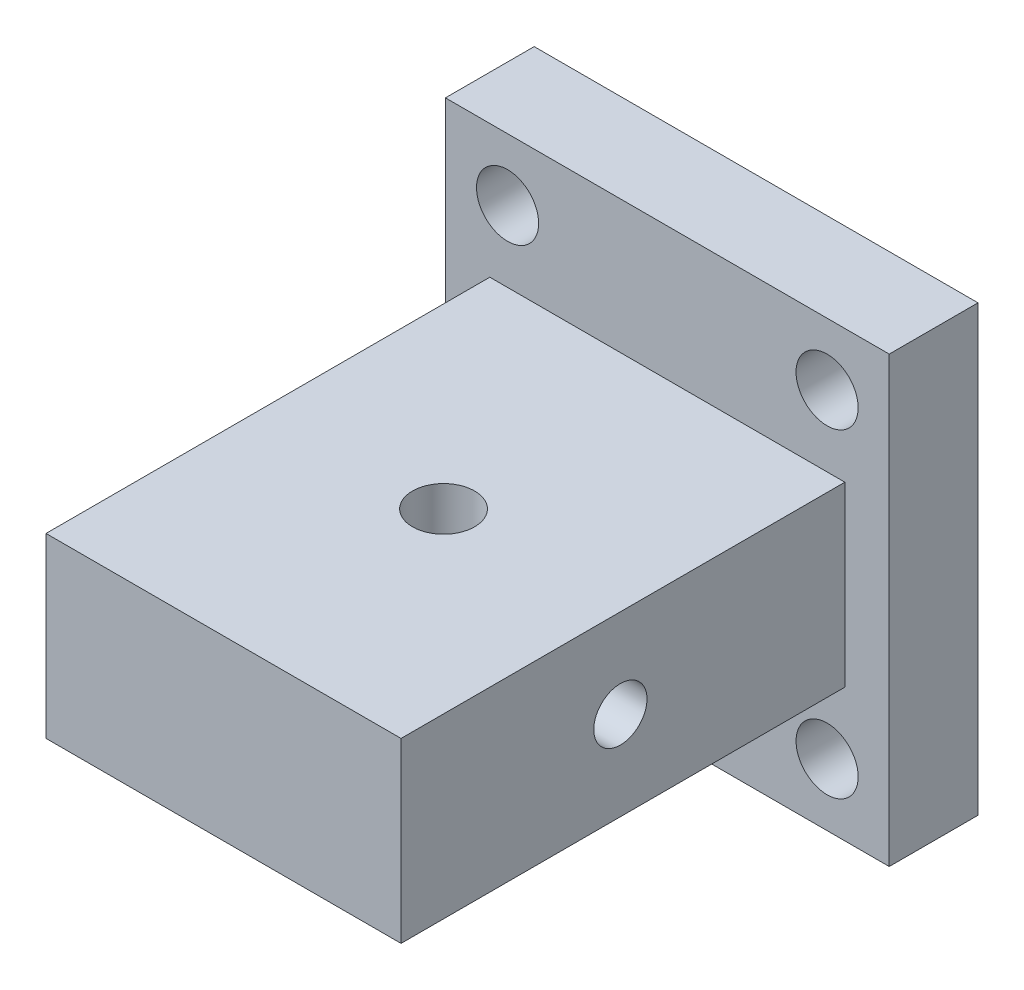
from build123d import *

# Parameters (mm, degrees)
SKETCH1_W           = 50
SKETCH1_H           = 50
BOSS_EXTRUDE1_DEPTH = 10
SKETCH2_W           = 40
SKETCH2_H           = 20
BOSS_EXTRUDE2_DEPTH = 50
SKETCH3_R           = 3.5
CUT_EXTRUDE1_DEPTH  = 10
SKETCH4_R           = 3
CUT_EXTRUDE2_DEPTH  = 46
SKETCH5_R           = 3.5
CUT_EXTRUDE3_DEPTH  = 10


with BuildPart() as part:
    # Sketch1 → Boss-Extrude1 (new body)
    with BuildSketch(Plane.XY):
        Rectangle(SKETCH1_W, SKETCH1_H)
    extrude(amount=BOSS_EXTRUDE1_DEPTH)

    # Sketch2 → Boss-Extrude2 (add)
    with BuildSketch(Plane.XY.offset(10)):
        Rectangle(SKETCH2_W, SKETCH2_H)
    extrude(amount=BOSS_EXTRUDE2_DEPTH)

    # Sketch3 → Cut-Extrude1 (cut)
    with BuildSketch(Plane.XY.offset(10)):
        with Locations((-18, 18)):
            Circle(SKETCH3_R)
        with Locations((18, 18)):
            Circle(SKETCH3_R)
        with Locations((18, -18)):
            Circle(SKETCH3_R)
        with Locations((-18, -18)):
            Circle(SKETCH3_R)
    extrude(amount=-CUT_EXTRUDE1_DEPTH, mode=Mode.SUBTRACT)

    # Sketch4 → Cut-Extrude2 (cut, through all)
    with BuildSketch(Plane(origin=(20, 0, 0), x_dir=(0, 0, -1), z_dir=(1, 0, 0))):
        with Locations((-35.289984846, 0)):
            Circle(SKETCH4_R)
    extrude(amount=-CUT_EXTRUDE2_DEPTH, mode=Mode.SUBTRACT)

    # Sketch5 → Cut-Extrude3 (cut)
    with BuildSketch(Plane(origin=(0, 10, 0), x_dir=(1, 0, 0), z_dir=(0, 1, 0))):
        with Locations((0, -35.211614701)):
            Circle(SKETCH5_R)
    extrude(amount=-CUT_EXTRUDE3_DEPTH, mode=Mode.SUBTRACT)


solid = part.part
